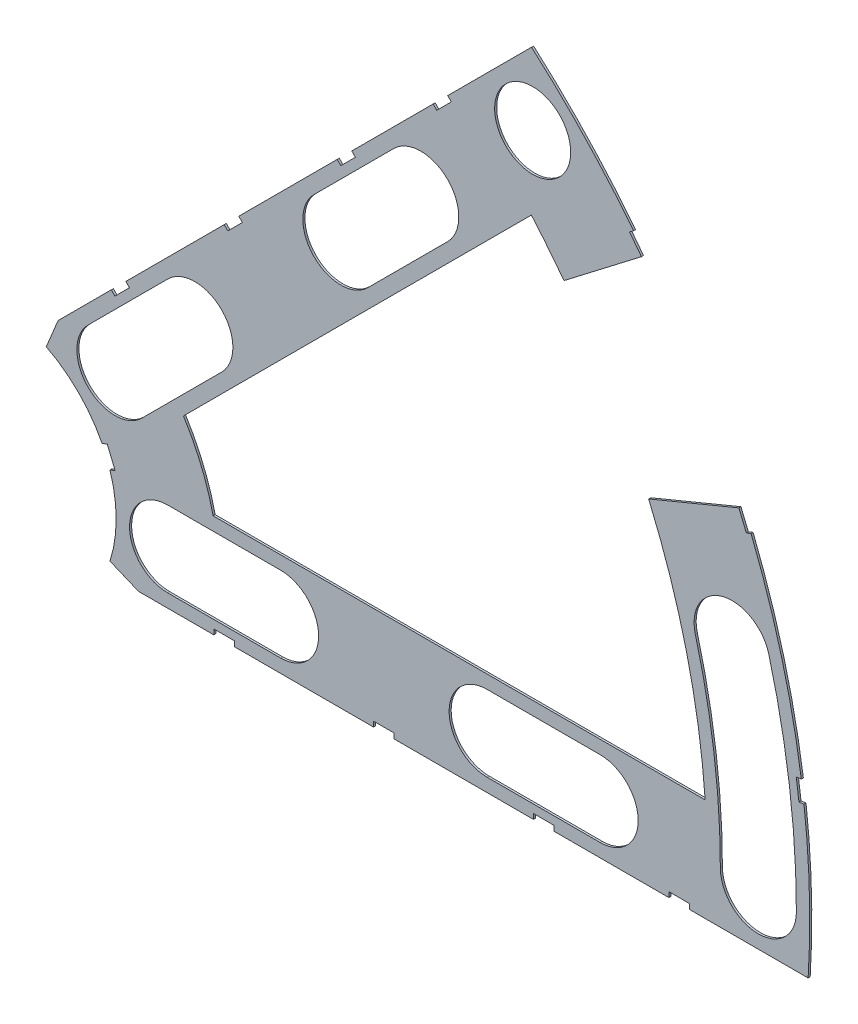
from build123d import *

# Parameters (mm, degrees)
BOSS_EXTRUDE1_DEPTH = 0.254
SKETCH2_R           = 4.699
CUT_EXTRUDE1_DEPTH  = 1.254
SKETCH3_W           = 2.54
SKETCH3_H           = 0.635
CUT_EXTRUDE2_DEPTH  = 1.254
CUT_EXTRUDE4_DEPTH  = 1.254
CUT_EXTRUDE5_DEPTH  = 1.254


with BuildPart() as part:
    # Sketch1 → Boss-Extrude1 (new body)
    with BuildSketch(Plane.XY):
        with BuildLine():
            Line((67.21146711, 76.191723231), (8.696654013, 17.676910134))
            Line((8.696654013, 17.676910134), (7.228954972, 14.133571205))
            ThreePointArc((7.228954972, 14.133571205), (14.666587579, 6.075099489), (15.105587123, -4.88230096))
            Line((15.105587123, -4.88230096), (18.648926052, -6.35))
            Line((18.648926052, -6.35), (101.401368334, -6.35))
            ThreePointArc((101.401368334, -6.35), (93.866160503, 38.880636728), (67.21146711, 76.191723231))
        make_face()
        with BuildLine():
            Line((88.672924278, 6.35), (27.86051193, 6.35))
            ThreePointArc((27.86051193, 6.35), (26.399857642, 10.93517908), (24.190484974, 15.210228852))
            Line((24.190484974, 15.210228852), (67.191354125, 58.211098004))
            ThreePointArc((67.191354125, 58.211098004), (82.13289044, 34.020557137), (88.672924278, 6.35))
        make_face(mode=Mode.SUBTRACT)
    extrude(amount=BOSS_EXTRUDE1_DEPTH)

    # Sketch2 → Cut-Extrude1 (cut, through all)
    with BuildSketch(Plane.XY.offset(0.254)):
        with Locations((22.225, 0)):
            Circle(SKETCH2_R)
        with Locations((36.195, 0)):
            Circle(SKETCH2_R)
        with Locations((61.722, 0)):
            Circle(SKETCH2_R)
        with Locations((75.692, 0)):
            Circle(SKETCH2_R)
        with Locations((95.25, 0)):
            Circle(SKETCH2_R)
        with Locations((15.715448212, 15.715448212)):
            Circle(SKETCH2_R)
        with Locations((25.593729945, 25.593729945)):
            Circle(SKETCH2_R)
        with Locations((43.644044748, 43.644044748)):
            Circle(SKETCH2_R)
        with Locations((53.522326482, 53.522326482)):
            Circle(SKETCH2_R)
        with Locations((92.004434954, 24.652514046)):
            Circle(SKETCH2_R)
        with Locations((82.48891971, 47.625)):
            Circle(SKETCH2_R)
        with Locations((67.351920908, 67.351920908)):
            Circle(SKETCH2_R)
    extrude(amount=-CUT_EXTRUDE1_DEPTH, mode=Mode.SUBTRACT)

    # Sketch3 → Cut-Extrude2 (cut, through all)
    with BuildSketch(Plane.XY.offset(0.254)):
        Polygon((15.266435406, 24.246691527), (17.06248663, 26.042742751), (17.511499436, 25.593729945), (15.715448212, 23.797678721), align=None)
        Polygon((44.991083167, 53.971339288), (43.195031942, 52.175288063), (43.644044748, 51.726275257), (45.440095973, 53.522326482), align=None)
        with Locations((29.21, -6.0325)):
            Rectangle(SKETCH3_W, SKETCH3_H)
        with Locations((68.707, -6.0325)):
            Rectangle(SKETCH3_W, SKETCH3_H)
        Polygon((29.230733674, 38.210989795), (31.026784898, 40.007041019), (31.475797704, 39.558028213), (29.67974648, 37.761976989), align=None)
        Polygon((56.845021246, 65.825277367), (55.048970022, 64.029226143), (55.497982828, 63.580213337), (57.294034052, 65.376264561), align=None)
        with Locations((48.9585, -6.0325)):
            Rectangle(SKETCH3_W, SKETCH3_H)
        with Locations((85.471, -6.0325)):
            Rectangle(SKETCH3_W, SKETCH3_H)
        Polygon((99.935462164, 14.437711971), (100.266998693, 11.919442024), (101.526133667, 12.085210288), (101.194597138, 14.603480236), align=None)
        Polygon((93.765504959, 37.464305742), (94.938831965, 37.950313702), (93.966816047, 40.296967714), (92.793489041, 39.810959755), align=None)
        Polygon((79.327792988, 62.471156422), (80.874047017, 60.456038938), (81.88160576, 61.229165953), (80.33535173, 63.244283437), align=None)
        Polygon((13.593916116, 7.005422516), (14.565932035, 4.658768503), (15.739259041, 5.144776462), (14.767243123, 7.491430475), align=None)
    extrude(amount=-CUT_EXTRUDE2_DEPTH, mode=Mode.SUBTRACT)

    # Sketch6 → Cut-Extrude4 (cut, through all)
    with BuildSketch(Plane.XY.offset(0.254)):
        with BuildLine():
            Line((12.392753447, 19.038142977), (22.27103518, 28.91642471))
            ThreePointArc((22.27103518, 28.91642471), (28.91642471, 28.91642471), (28.91642471, 22.27103518))
            Line((28.91642471, 22.27103518), (19.038142977, 12.392753447))
            ThreePointArc((19.038142977, 12.392753447), (12.392753447, 12.392753447), (12.392753447, 19.038142977))
        make_face()
        with BuildLine():
            Line((40.321349984, 46.966739513), (50.199631717, 56.845021246))
            ThreePointArc((50.199631717, 56.845021246), (56.845021246, 56.845021246), (56.845021246, 50.199631717))
            Line((56.845021246, 50.199631717), (46.966739513, 40.321349984))
            ThreePointArc((46.966739513, 40.321349984), (40.321349984, 40.321349984), (40.321349984, 46.966739513))
        make_face()
        with BuildLine():
            Line((22.225, 4.699), (36.195, 4.699))
            ThreePointArc((36.195, 4.699), (40.894, 0), (36.195, -4.699))
            Line((36.195, -4.699), (22.225, -4.699))
            ThreePointArc((22.225, -4.699), (17.526, 0), (22.225, 4.699))
        make_face()
        with BuildLine():
            Line((61.722, 4.699), (75.692, 4.699))
            ThreePointArc((75.692, 4.699), (80.391, 0), (75.692, -4.699))
            Line((75.692, -4.699), (61.722, -4.699))
            ThreePointArc((61.722, -4.699), (57.023, 0), (61.722, 4.699))
        make_face()
        with BuildLine():
            ThreePointArc((99.949, 0), (99.093922449, 13.045962386), (96.543320412, 25.868704739))
            ThreePointArc((96.543320412, 25.868704739), (90.788244261, 29.191399504), (87.465549496, 23.436323353))
            ThreePointArc((87.465549496, 23.436323353), (89.776323642, 11.819277232), (90.551, 0))
            ThreePointArc((90.551, 0), (95.25, -4.699), (99.949, 0))
        make_face()
    extrude(amount=-CUT_EXTRUDE4_DEPTH, mode=Mode.SUBTRACT)

    # Sketch5 → Cut-Extrude5 (cut, through all)
    with BuildSketch(Plane.XY.offset(0.254)):
        with BuildLine():
            Line((70.21145334, 52.434423044), (82.30303448, 61.71261958))
            ThreePointArc((82.30303448, 61.71261958), (89.088033287, 51.435), (94.59621353, 40.420208878))
            Line((94.59621353, 40.420208878), (80.515269058, 34.587690707))
            ThreePointArc((80.515269058, 34.587690707), (75.889806134, 43.815), (70.21145334, 52.434423044))
        make_face()
    extrude(amount=-CUT_EXTRUDE5_DEPTH, mode=Mode.SUBTRACT)


solid = part.part
